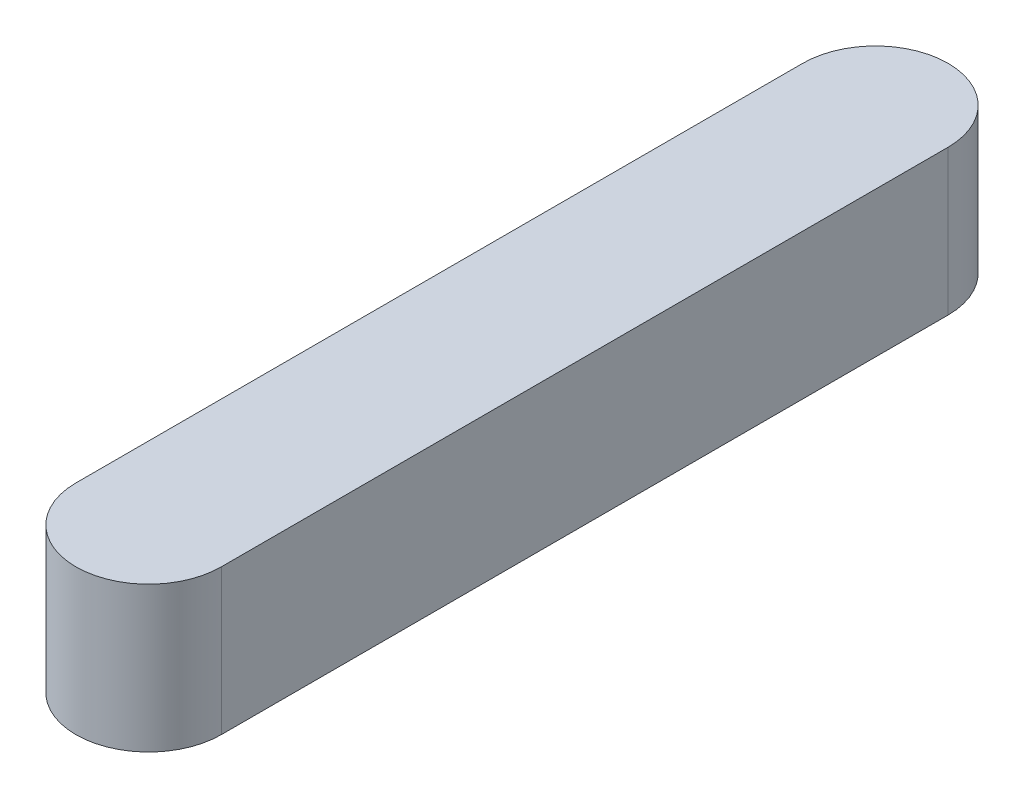
from build123d import *

# Parameters (mm, degrees)
BOSS_EXTRU_1_DEPTH = 10


with BuildPart() as part:
    # Esquisse1 → Boss.-Extru.1 (new body)
    with BuildSketch(Plane(origin=(0, 0, 0), x_dir=(1, 0, 0), z_dir=(0, 1, 0))):
        with BuildLine():
            Line((5, 0), (5, -50))
            ThreePointArc((5, -50), (0, -55), (-5, -50))
            Line((-5, -50), (-5, 0))
            ThreePointArc((-5, 0), (0, 5), (5, 0))
        make_face()
    extrude(amount=BOSS_EXTRU_1_DEPTH)


solid = part.part
